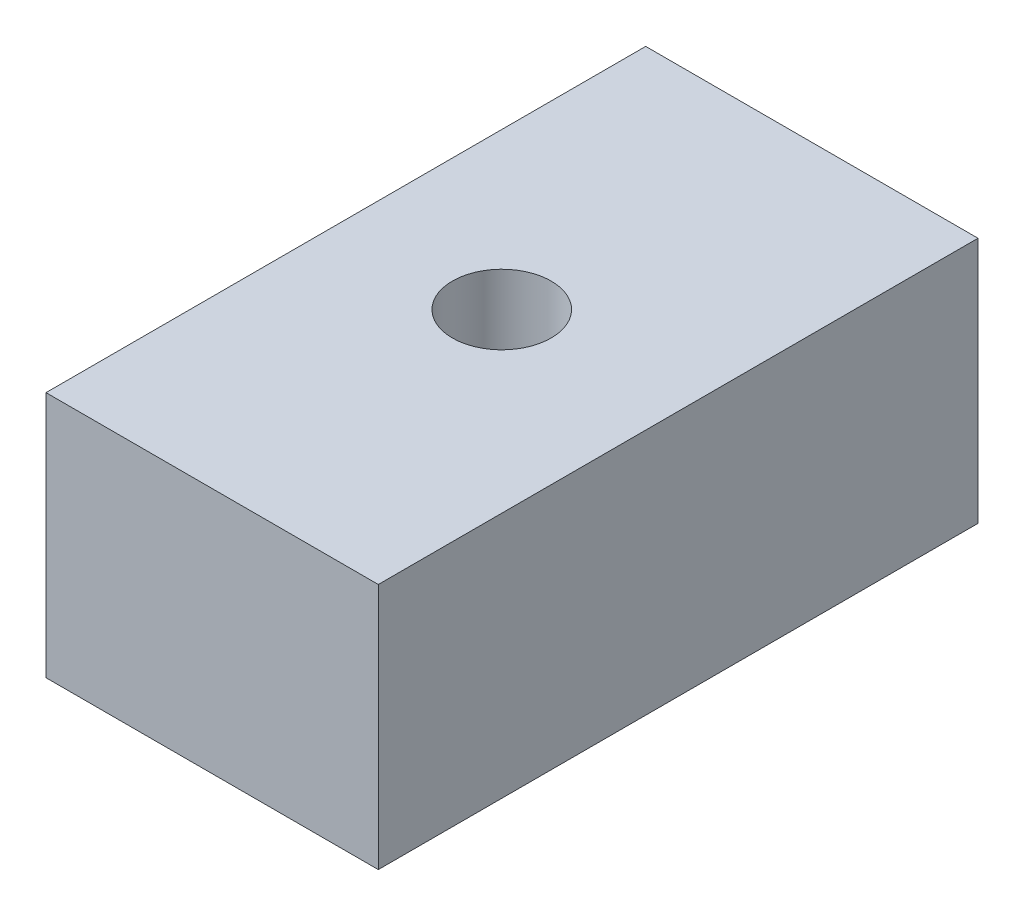
from build123d import *

# Parameters (mm, degrees)
ESBO_O1_W                = 9.42
ESBO_O1_H                = 17
ESBO_O1_R                = 1.4
RESSALTO_EXTRUS_O1_DEPTH = 7


with BuildPart() as part:
    # Esboço1 → Ressalto-extrusão1 (new body)
    with BuildSketch(Plane(origin=(0, 0, 0), x_dir=(1, 0, 0), z_dir=(0, 1, 0))):
        with Locations((4.71, 8.5)):
            Rectangle(ESBO_O1_W, ESBO_O1_H)
        with Locations((4.42, 8.5)):
            Circle(ESBO_O1_R, mode=Mode.SUBTRACT)
    extrude(amount=RESSALTO_EXTRUS_O1_DEPTH)


solid = part.part
